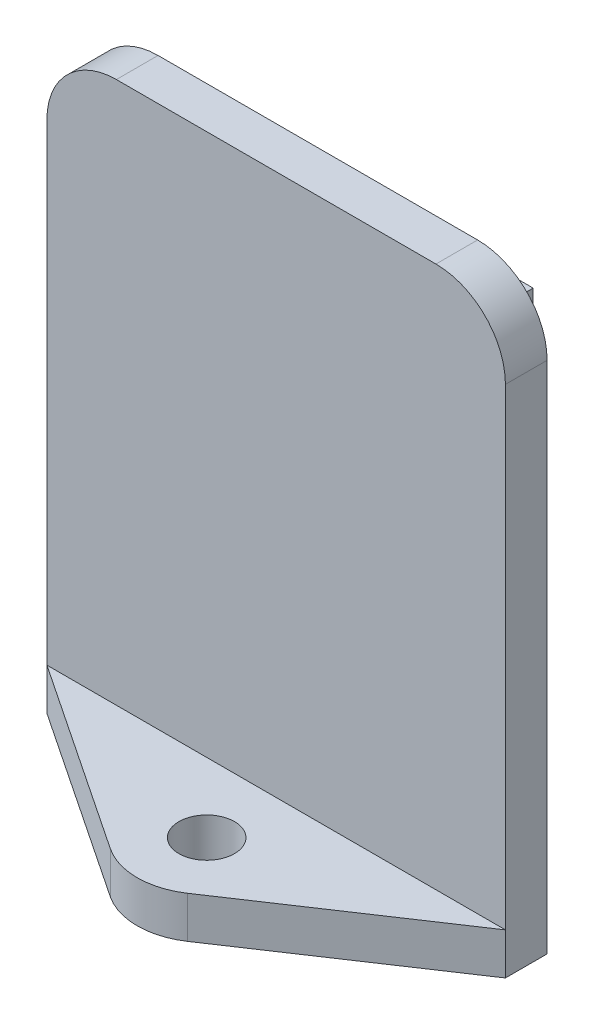
from build123d import *

# Parameters (mm, degrees)
EXTRUDE_1_DEPTH = 3
SKETCH_2_R      = 2
EXTRUDE_2_DEPTH = 3
SKETCH_3_W      = 27
SKETCH_3_H      = 39
EXTRUDE_3_DEPTH = 2


with BuildPart() as part:
    # 草图1 → 凸台-拉伸1 (new body)
    with BuildSketch(Plane.XY):
        with BuildLine():
            Line((11.5, 23.5), (-11.5, 23.5))
            ThreePointArc((-11.5, 23.5), (-15.035533906, 22.035533906), (-16.5, 18.5))
            Line((-16.5, 18.5), (-16.5, -18.5))
            Line((-16.5, -18.5), (16.5, -18.5))
            Line((16.5, -18.5), (16.5, 18.5))
            ThreePointArc((16.5, 18.5), (15.035533906, 22.035533906), (11.5, 23.5))
        make_face()
    extrude(amount=EXTRUDE_1_DEPTH)

    # 草图2 → 凸台-拉伸2 (add)
    with BuildSketch(Plane.XZ.offset(18.5)):
        with BuildLine():
            ThreePointArc((-1.2e-08, 3), (-4.785122024, 6.549963029), (-2.775441548, 12.158957107))
            Line((-2.775441548, 12.158957107), (-16.5, 3))
            Line((-16.5, 3), (-1.2e-08, 3))
        make_face()
        with BuildLine():
            Line((16.5, 3), (2.775441548, 12.158957107))
            ThreePointArc((2.775441548, 12.158957107), (4.40892321, 10.358261252), (5, 8))
            ThreePointArc((5, 8), (3.535533902, 4.46446609), (-1.2e-08, 3))
            Line((-1.2e-08, 3), (16.5, 3))
        make_face()
        with BuildLine():
            ThreePointArc((2.775441548, 12.158957107), (0, 13), (-2.775441548, 12.158957107))
            ThreePointArc((-2.775441548, 12.158957107), (-4.785122024, 6.549963029), (-1.2e-08, 3))
            ThreePointArc((-1.2e-08, 3), (3.535533902, 4.46446609), (5, 8))
            ThreePointArc((5, 8), (4.40892321, 10.358261252), (2.775441548, 12.158957107))
        make_face()
        with Locations(Location((0, 8, 0), (0, 0, 270))):
            Circle(SKETCH_2_R, mode=Mode.SUBTRACT)
    extrude(amount=-EXTRUDE_2_DEPTH)

    # 草图3 → 凸台-拉伸3 (add)
    with BuildSketch(Plane(origin=(0, 0, 0), x_dir=(-1, 0, 0), z_dir=(0, 0, -1))):
        with Locations((0, 1)):
            Rectangle(SKETCH_3_W, SKETCH_3_H)
    extrude(amount=EXTRUDE_3_DEPTH)


solid = part.part
